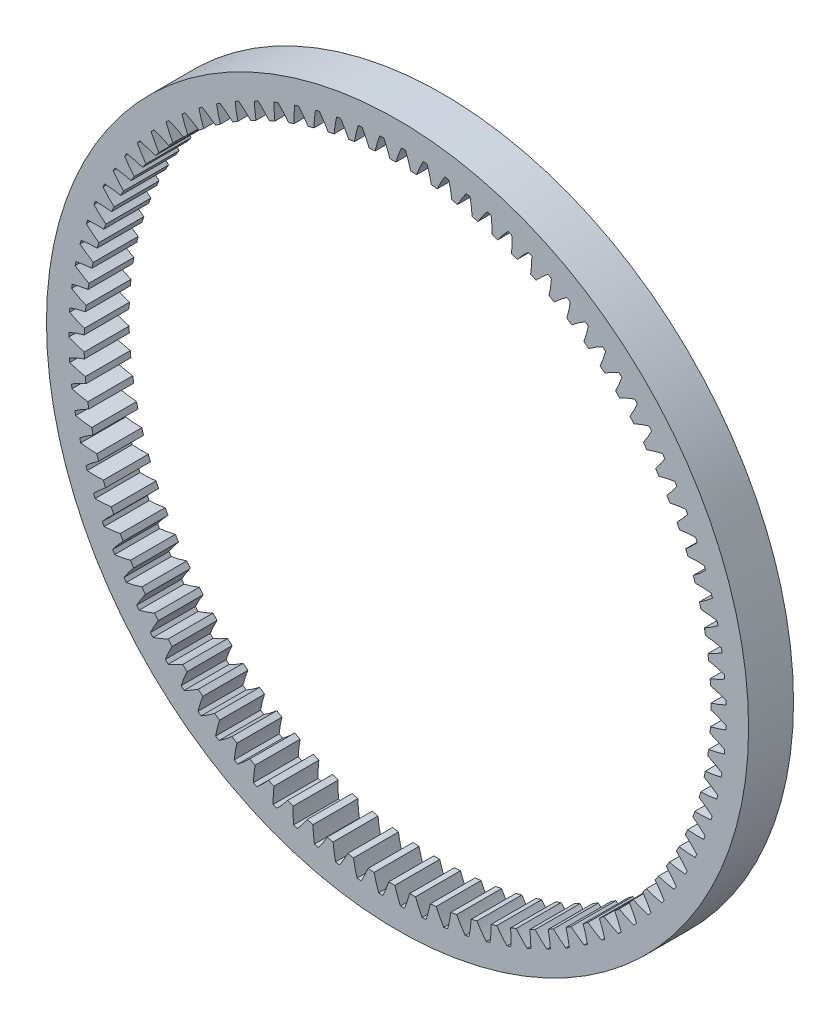
from build123d import *

# Parameters (mm, degrees)
SKICA2_R                 = 78.125
SKICA2_R_2               = 69.75
P_IDAT_VYSUNUT_M1_DEPTH  = 5
ODEBRAT_VYSUNUT_M2_DEPTH = 11
KRUHOV_POLE1_COUNT       = 95


with BuildPart() as part:
    # Skica2 → Přidat vysunutím1 (new body, symmetric)
    with BuildSketch(Plane.XY):
        Circle(SKICA2_R)
        Circle(SKICA2_R_2, mode=Mode.SUBTRACT)
    extrude(amount=P_IDAT_VYSUNUT_M1_DEPTH, both=True)

    # Skica3 → Odebrat vysunutím2 (cut, through all)
    with BuildSketch(Plane.XY.offset(5)):
        with BuildLine():
            ThreePointArc((69.747822011, 0.551203036), (69.715531817, 2.192515338), (69.644623458, 3.83261312))
            add(Edge.make_bspline(
                [(69.644623458, 3.83261312), (69.761537508, 3.805339375), (70.029282895, 3.740564499), (70.446221466, 3.63172946), (71.009524038, 3.468955894), (71.602093176, 3.280952637), (72.192946997, 3.077575863), (72.633186105, 2.914630637), (72.926040361, 2.801349661), (73.073532629, 2.743073838)],
                knots=[0.12570182, 0.12570182, 0.12570182, 0.12570182, 0.12570182, 0.146842496, 0.174208854, 0.201574956, 0.228941013, 0.256307345, 0.284233723, 0.284233723, 0.284233723, 0.284233723, 0.284233723], degree=4))
            ThreePointArc((73.073532629, 2.743073838), (73.088864001, 2.29860479), (73.10149192, 1.85405072))
            add(Edge.make_bspline(
                [(69.747822011, 0.551203036), (69.862791223, 0.585769383), (70.125937253, 0.667240503), (70.535213037, 0.802059532), (71.087174258, 0.999907534), (71.666758857, 1.224774384), (72.243665507, 1.464876587), (72.672795674, 1.655163), (72.957952987, 1.786622125), (73.10149192, 1.85405072)],
                knots=[0.12570182, 0.12570182, 0.12570182, 0.12570182, 0.12570182, 0.146842496, 0.174208854, 0.201574956, 0.228941013, 0.256307345, 0.284233723, 0.284233723, 0.284233723, 0.284233723, 0.284233723], degree=4))
        make_face()
    odebrat_vysunut_m2 = extrude(amount=-ODEBRAT_VYSUNUT_M2_DEPTH, mode=Mode.SUBTRACT)

    # Kruhové pole1: Odebrat vysunutím2 ×95 about axis
    kruhov_pole1_axis = Axis((0, 0, 5), (0, 0, -1))
    for i in range(1, KRUHOV_POLE1_COUNT):
        add(odebrat_vysunut_m2.rotate(kruhov_pole1_axis, i * 360 / KRUHOV_POLE1_COUNT), mode=Mode.SUBTRACT)


solid = part.part
